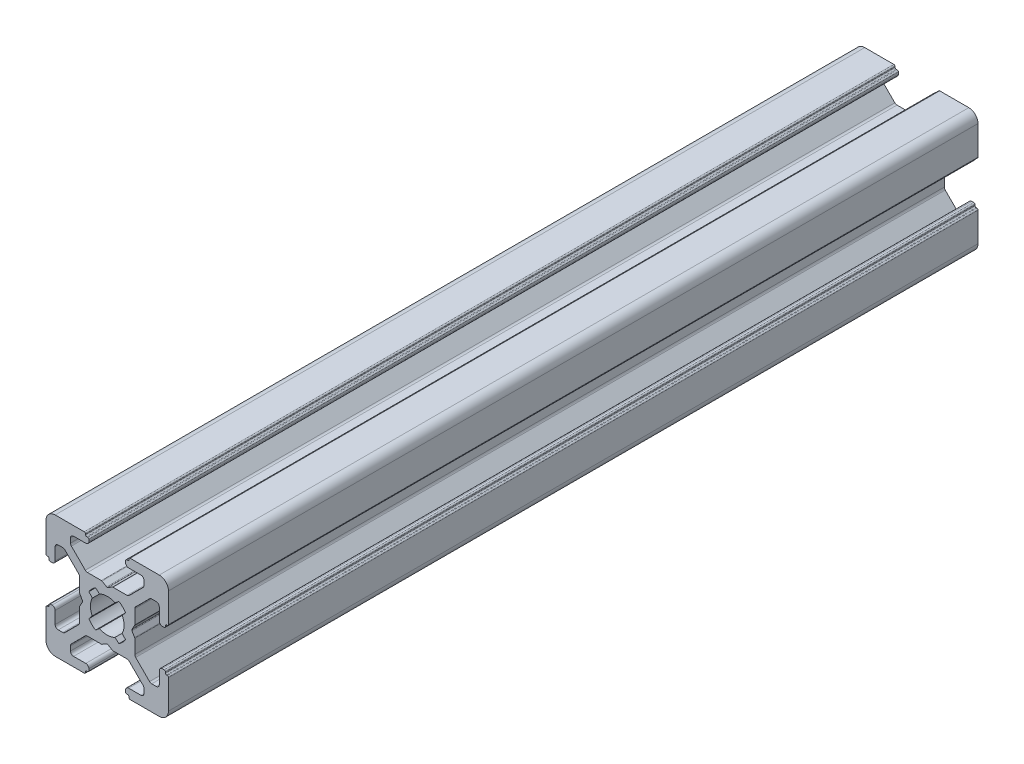
from build123d import *

# Parameters (mm, degrees)
EXTRUDE1_DEPTH = 132.23


with BuildPart() as part:
    # Sketch1 → Extrude1 (new body)
    with BuildSketch(Plane.XY):
        with BuildLine():
            Line((-3.5, 8.499999673), (-5.500000686, 8.499999673))
            ThreePointArc((-5.500000686, 8.499999673), (-5.853554077, 8.353553064), (-6.000000686, 7.999999673))
            Line((-6.000000686, 7.999999673), (-6.000000686, 7.267766626))
            ThreePointArc((-6.000000686, 7.267766626), (-5.961940448, 7.076424899), (-5.853554059, 6.914213219))
            Line((-5.853554059, 6.914213219), (-3.585787212, 4.646446592))
            ThreePointArc((-3.585787212, 4.646446592), (-3.423575544, 4.538060229), (-3.232233839, 4.5))
            Line((-3.232233839, 4.5), (-0.953590312, 4.5))
            ThreePointArc((-0.953590312, 4.5), (-0.901826505, 4.493185166), (-0.853590316, 4.473205083))
            Line((-0.853590316, 4.473205083), (-0.100000045, 4.038119562))
            ThreePointArc((-0.100000045, 4.038119562), (0, 4.011324632), (0.100000045, 4.038119562))
            Line((0.100000045, 4.038119562), (0.853590316, 4.473205083))
            ThreePointArc((0.853590316, 4.473205083), (0.901826505, 4.493185166), (0.953590312, 4.5))
            Line((0.953590312, 4.5), (3.232233839, 4.5))
            ThreePointArc((3.232233839, 4.5), (3.423575544, 4.538060229), (3.585787212, 4.646446592))
            Line((3.585787212, 4.646446592), (5.853554059, 6.914213219))
            ThreePointArc((5.853554059, 6.914213219), (5.961940448, 7.076424899), (6.000000686, 7.267766626))
            Line((6.000000686, 7.267766626), (6.000000686, 7.999999673))
            ThreePointArc((6.000000686, 7.999999673), (5.853554077, 8.353553064), (5.500000686, 8.499999673))
            Line((5.500000686, 8.499999673), (3.5, 8.499999673))
            ThreePointArc((3.5, 8.499999673), (3.146446609, 8.646446283), (3, 8.999999673))
            Line((3, 8.999999673), (3, 9.3))
            ThreePointArc((3, 9.3), (3.058578644, 9.441421356), (3.2, 9.5))
            Line((3.2, 9.5), (3.350000228, 9.5))
            ThreePointArc((3.350000228, 9.5), (3.491421584, 9.558578644), (3.550000228, 9.7))
            Line((3.550000228, 9.7), (3.550000228, 9.8))
            ThreePointArc((3.550000228, 9.8), (3.608578871, 9.941421356), (3.750000228, 10))
            Line((3.750000228, 10), (8.5, 10))
            ThreePointArc((8.5, 10), (9.560660172, 9.560660172), (10, 8.5))
            Line((10, 8.5), (10, 3.749999605))
            ThreePointArc((10, 3.749999605), (9.941421356, 3.608578248), (9.8, 3.549999605))
            Line((9.8, 3.549999605), (9.699999732, 3.549999605))
            ThreePointArc((9.699999732, 3.549999605), (9.558578376, 3.491420961), (9.499999732, 3.349999605))
            Line((9.499999732, 3.349999605), (9.499999732, 3.2))
            ThreePointArc((9.499999732, 3.2), (9.441421088, 3.058578644), (9.299999732, 3))
            Line((9.299999732, 3), (8.999999732, 3))
            ThreePointArc((8.999999732, 3), (8.646446341, 3.146446609), (8.499999732, 3.5))
            Line((8.499999732, 3.5), (8.499999732, 5.499999605))
            ThreePointArc((8.499999732, 5.499999605), (8.353553123, 5.853552995), (7.999999732, 5.999999605))
            Line((7.999999732, 5.999999605), (7.267766685, 5.999999605))
            ThreePointArc((7.267766685, 5.999999605), (7.076424969, 5.961939371), (6.914213294, 5.853552995))
            Line((6.914213294, 5.853552995), (4.646446398, 3.585786099))
            ThreePointArc((4.646446398, 3.585786099), (4.538060023, 3.423574425), (4.499999789, 3.232232708))
            Line((4.499999789, 3.232232708), (4.499999789, 0.953589302))
            ThreePointArc((4.499999789, 0.953589302), (4.493184953, 0.90182549), (4.473204867, 0.853589297))
            Line((4.473204867, 0.853589297), (4.038119841, 0.099999969))
            ThreePointArc((4.038119841, 0.099999969), (4.011324929, 0), (4.038119841, -0.099999969))
            Line((4.038119841, -0.099999969), (4.473204867, -0.853589297))
            ThreePointArc((4.473204867, -0.853589297), (4.493184953, -0.90182549), (4.499999789, -0.953589302))
            Line((4.499999789, -0.953589302), (4.499999789, -3.232232708))
            ThreePointArc((4.499999789, -3.232232708), (4.538060023, -3.423574425), (4.646446398, -3.585786099))
            Line((4.646446398, -3.585786099), (6.914213294, -5.853552995))
            ThreePointArc((6.914213294, -5.853552995), (7.076424969, -5.961939371), (7.267766685, -5.999999605))
            Line((7.267766685, -5.999999605), (7.999999732, -5.999999605))
            ThreePointArc((7.999999732, -5.999999605), (8.353553123, -5.853552995), (8.499999732, -5.499999605))
            Line((8.499999732, -5.499999605), (8.499999732, -3.5))
            ThreePointArc((8.499999732, -3.5), (8.646446341, -3.146446609), (8.999999732, -3))
            Line((8.999999732, -3), (9.299999732, -3))
            ThreePointArc((9.299999732, -3), (9.441421088, -3.058578644), (9.499999732, -3.2))
            Line((9.499999732, -3.2), (9.499999732, -3.349999605))
            ThreePointArc((9.499999732, -3.349999605), (9.558578376, -3.491420961), (9.699999732, -3.549999605))
            Line((9.699999732, -3.549999605), (9.8, -3.549999605))
            ThreePointArc((9.8, -3.549999605), (9.941421356, -3.608578248), (10, -3.749999605))
            Line((10, -3.749999605), (10, -8.5))
            ThreePointArc((10, -8.5), (9.560660172, -9.560660172), (8.5, -10))
            Line((8.5, -10), (3.750000228, -10))
            ThreePointArc((3.750000228, -10), (3.608578871, -9.941421356), (3.550000228, -9.8))
            Line((3.550000228, -9.8), (3.550000228, -9.7))
            ThreePointArc((3.550000228, -9.7), (3.491421584, -9.558578644), (3.350000228, -9.5))
            Line((3.350000228, -9.5), (3.2, -9.5))
            ThreePointArc((3.2, -9.5), (3.058578644, -9.441421356), (3, -9.3))
            Line((3, -9.3), (3, -8.999999673))
            ThreePointArc((3, -8.999999673), (3.146446609, -8.646446283), (3.5, -8.499999673))
            Line((3.5, -8.499999673), (5.500000686, -8.499999673))
            ThreePointArc((5.500000686, -8.499999673), (5.853554077, -8.353553064), (6.000000686, -7.999999673))
            Line((6.000000686, -7.999999673), (6.000000686, -7.267766626))
            ThreePointArc((6.000000686, -7.267766626), (5.961940448, -7.076424899), (5.853554059, -6.914213219))
            Line((5.853554059, -6.914213219), (3.585787212, -4.646446592))
            ThreePointArc((3.585787212, -4.646446592), (3.423575544, -4.538060229), (3.232233839, -4.5))
            Line((3.232233839, -4.5), (0.953590312, -4.5))
            ThreePointArc((0.953590312, -4.5), (0.901826505, -4.493185166), (0.853590316, -4.473205083))
            Line((0.853590316, -4.473205083), (0.100000045, -4.038119562))
            ThreePointArc((0.100000045, -4.038119562), (0, -4.011324632), (-0.100000045, -4.038119562))
            Line((-0.100000045, -4.038119562), (-0.853590316, -4.473205083))
            ThreePointArc((-0.853590316, -4.473205083), (-0.901826505, -4.493185166), (-0.953590312, -4.5))
            Line((-0.953590312, -4.5), (-3.232233839, -4.5))
            ThreePointArc((-3.232233839, -4.5), (-3.423575544, -4.538060229), (-3.585787212, -4.646446592))
            Line((-3.585787212, -4.646446592), (-5.853554059, -6.914213219))
            ThreePointArc((-5.853554059, -6.914213219), (-5.961940448, -7.076424899), (-6.000000686, -7.267766626))
            Line((-6.000000686, -7.267766626), (-6.000000686, -7.999999673))
            ThreePointArc((-6.000000686, -7.999999673), (-5.853554077, -8.353553064), (-5.500000686, -8.499999673))
            Line((-5.500000686, -8.499999673), (-3.5, -8.499999673))
            ThreePointArc((-3.5, -8.499999673), (-3.146446609, -8.646446283), (-3, -8.999999673))
            Line((-3, -8.999999673), (-3, -9.3))
            ThreePointArc((-3, -9.3), (-3.058578644, -9.441421356), (-3.2, -9.5))
            Line((-3.2, -9.5), (-3.350000228, -9.5))
            ThreePointArc((-3.350000228, -9.5), (-3.491421584, -9.558578644), (-3.550000228, -9.7))
            Line((-3.550000228, -9.7), (-3.550000228, -9.8))
            ThreePointArc((-3.550000228, -9.8), (-3.608578871, -9.941421356), (-3.750000228, -10))
            Line((-3.750000228, -10), (-8.5, -10))
            ThreePointArc((-8.5, -10), (-9.560660172, -9.560660172), (-10, -8.5))
            Line((-10, -8.5), (-10, -3.749999605))
            ThreePointArc((-10, -3.749999605), (-9.941421356, -3.608578248), (-9.8, -3.549999605))
            Line((-9.8, -3.549999605), (-9.699999732, -3.549999605))
            ThreePointArc((-9.699999732, -3.549999605), (-9.558578376, -3.491420961), (-9.499999732, -3.349999605))
            Line((-9.499999732, -3.349999605), (-9.499999732, -3.2))
            ThreePointArc((-9.499999732, -3.2), (-9.441421088, -3.058578644), (-9.299999732, -3))
            Line((-9.299999732, -3), (-8.999999732, -3))
            ThreePointArc((-8.999999732, -3), (-8.646446341, -3.146446609), (-8.499999732, -3.5))
            Line((-8.499999732, -3.5), (-8.499999732, -5.499999605))
            ThreePointArc((-8.499999732, -5.499999605), (-8.353553123, -5.853552995), (-7.999999732, -5.999999605))
            Line((-7.999999732, -5.999999605), (-7.267766685, -5.999999605))
            ThreePointArc((-7.267766685, -5.999999605), (-7.076424969, -5.961939371), (-6.914213294, -5.853552995))
            Line((-6.914213294, -5.853552995), (-4.646446398, -3.585786099))
            ThreePointArc((-4.646446398, -3.585786099), (-4.538060023, -3.423574425), (-4.499999789, -3.232232708))
            Line((-4.499999789, -3.232232708), (-4.499999789, -0.953589302))
            ThreePointArc((-4.499999789, -0.953589302), (-4.493184953, -0.90182549), (-4.473204867, -0.853589297))
            Line((-4.473204867, -0.853589297), (-4.038119841, -0.099999969))
            ThreePointArc((-4.038119841, -0.099999969), (-4.011324929, 0), (-4.038119841, 0.099999969))
            Line((-4.038119841, 0.099999969), (-4.473204867, 0.853589297))
            ThreePointArc((-4.473204867, 0.853589297), (-4.493184953, 0.90182549), (-4.499999789, 0.953589302))
            Line((-4.499999789, 0.953589302), (-4.499999789, 3.232232708))
            ThreePointArc((-4.499999789, 3.232232708), (-4.538060023, 3.423574425), (-4.646446398, 3.585786099))
            Line((-4.646446398, 3.585786099), (-6.914213294, 5.853552995))
            ThreePointArc((-6.914213294, 5.853552995), (-7.076424969, 5.961939371), (-7.267766685, 5.999999605))
            Line((-7.267766685, 5.999999605), (-7.999999732, 5.999999605))
            ThreePointArc((-7.999999732, 5.999999605), (-8.353553123, 5.853552995), (-8.499999732, 5.499999605))
            Line((-8.499999732, 5.499999605), (-8.499999732, 3.5))
            ThreePointArc((-8.499999732, 3.5), (-8.646446341, 3.146446609), (-8.999999732, 3))
            Line((-8.999999732, 3), (-9.299999732, 3))
            ThreePointArc((-9.299999732, 3), (-9.441421088, 3.058578644), (-9.499999732, 3.2))
            Line((-9.499999732, 3.2), (-9.499999732, 3.349999605))
            ThreePointArc((-9.499999732, 3.349999605), (-9.558578376, 3.491420961), (-9.699999732, 3.549999605))
            Line((-9.699999732, 3.549999605), (-9.8, 3.549999605))
            ThreePointArc((-9.8, 3.549999605), (-9.941421356, 3.608578248), (-10, 3.749999605))
            Line((-10, 3.749999605), (-10, 8.5))
            ThreePointArc((-10, 8.5), (-9.560660172, 9.560660172), (-8.5, 10))
            Line((-8.5, 10), (-3.750000228, 10))
            ThreePointArc((-3.750000228, 10), (-3.608578871, 9.941421356), (-3.550000228, 9.8))
            Line((-3.550000228, 9.8), (-3.550000228, 9.7))
            ThreePointArc((-3.550000228, 9.7), (-3.491421584, 9.558578644), (-3.350000228, 9.5))
            Line((-3.350000228, 9.5), (-3.2, 9.5))
            ThreePointArc((-3.2, 9.5), (-3.058578644, 9.441421356), (-3, 9.3))
            Line((-3, 9.3), (-3, 8.999999673))
            ThreePointArc((-3, 8.999999673), (-3.146446609, 8.646446283), (-3.5, 8.499999673))
        make_face()
        with BuildLine():
            Line((-1.258185436, 2.445295362), (-1.91389502, 2.989640962))
            ThreePointArc((-1.91389502, 2.989640962), (-2.511737261, 2.508410485), (-2.992174953, 1.909930962))
            Line((-2.992174953, 1.909930962), (-2.445295423, 1.258185317))
            ThreePointArc((-2.445295423, 1.258185317), (-2.75, 0), (-2.445295423, -1.258185317))
            Line((-2.445295423, -1.258185317), (-2.992174953, -1.909930962))
            ThreePointArc((-2.992174953, -1.909930962), (-2.511737261, -2.508410485), (-1.91389502, -2.989640962))
            Line((-1.91389502, -2.989640962), (-1.258185436, -2.445295362))
            ThreePointArc((-1.258185436, -2.445295362), (0, -2.75), (1.258185436, -2.445295362))
            Line((1.258185436, -2.445295362), (1.91389502, -2.989640962))
            ThreePointArc((1.91389502, -2.989640962), (2.511737261, -2.508410485), (2.992174953, -1.909930962))
            Line((2.992174953, -1.909930962), (2.445295423, -1.258185317))
            ThreePointArc((2.445295423, -1.258185317), (2.75, 0), (2.445295423, 1.258185317))
            Line((2.445295423, 1.258185317), (2.992174953, 1.909930962))
            ThreePointArc((2.992174953, 1.909930962), (2.511737261, 2.508410485), (1.91389502, 2.989640962))
            Line((1.91389502, 2.989640962), (1.258185436, 2.445295362))
            ThreePointArc((1.258185436, 2.445295362), (0, 2.75), (-1.258185436, 2.445295362))
        make_face(mode=Mode.SUBTRACT)
    extrude(amount=EXTRUDE1_DEPTH)


solid = part.part
